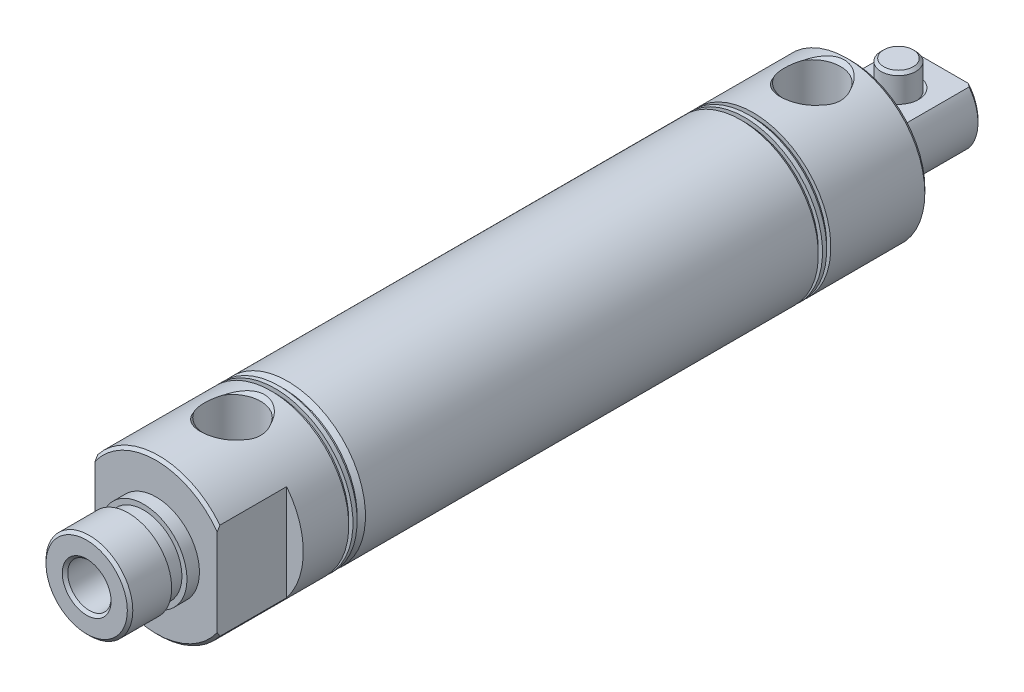
from build123d import *

# Parameters (mm, degrees)
SKETCH1_R           = 14.224
EXTRUDE1_DEPTH      = 71.4375
EXTRUDE1_DEPTH_BACK = 71.4375
SKETCH3_W           = 0.762
SKETCH3_H           = 0.762
RODHOLE_START       = -112.0375
SKETCH8_R           = 3.9624
RODHOLE_DEPTH       = 112.0375
SKETCH9_R           = 13.49375
STROKECHAMBER_DEPTH = 55.8
CHAMFER1_SIZE       = 0.5
SKETCH4_W           = 3.048
SKETCH4_H           = 12.7
SKETCH4_W_2         = 0.5
SKETCH4_H_2         = 6.096
FLATS_DEPTH         = 15.2240001
FLATS_DEPTH_BACK    = 15.2240001
SKETCH12_W          = 9.398
SKETCH12_H          = 15.375
ENDFLATS_DEPTH      = 15.2240001
ENDFLATS_DEPTH_BACK = 15.2240001


with BuildPart() as part:
    # Sketch1 → Extrude1 (new body, two sides)
    with BuildSketch(Plane.XY) as extrude1_sk:
        Circle(SKETCH1_R)
    extrude(amount=EXTRUDE1_DEPTH)
    extrude(extrude1_sk.sketch, amount=-EXTRUDE1_DEPTH_BACK)

    # Sketch2 → Nose (revolve)
    with BuildSketch(Plane(origin=(0, 0, 0), x_dir=(0, 0, -1), z_dir=(1, 0, 0))):
        Polygon((-71.4375, 7.9248), (-73.7235, 7.9248), (-73.7235, 7), (-76.5235, 7), (-76.5235, 7.9375), (-84.1375, 7.9375), (-84.1375, 0), (-71.4375, 0), align=None)
    revolve(axis=Axis((0, 0, 0), (0, 0, 1)))

    # Sketch3 → CoverGrooves (revolve, cut)
    with BuildSketch(Plane(origin=(0, 0, 0), x_dir=(0, 0, -1), z_dir=(1, 0, 0))):
        with Locations((-50.038, 13.843)):
            Rectangle(SKETCH3_W, SKETCH3_H)
        Polygon((-48.895, 14.224), (-48.895, 13.462), (-48.133, 13.462), (-47.371, 14.224), align=None)
        Polygon((37.7405, 14.224), (37.7405, 13.462), (36.9785, 14.224), align=None)
        Polygon((36.2165, 14.224), (36.2165, 13.462), (35.4545, 14.224), align=None)
    revolve(axis=Axis((0, 0, 0), (0, 0, 1)), mode=Mode.SUBTRACT)

    # Sketch7 → FrontPort (revolve, cut)
    with BuildSketch(Plane(origin=(0, 0, 0), x_dir=(0, 0, -1), z_dir=(1, 0, 0))):
        Polygon((-57.4675, 14.224), (-51.6175, 14.224), (-52.3175, 13.524), (-52.3175, 0), (-57.4675, 0), align=None)
    revolve(axis=Axis((0, 0, 57.4675), (0, 1, 0)), mode=Mode.SUBTRACT)

    # Sketch8 → RodHole (cut)
    with BuildSketch(Plane.XY.offset(84.1375).offset(RODHOLE_START)):
        Circle(SKETCH8_R)
    extrude(amount=RODHOLE_DEPTH, mode=Mode.SUBTRACT)

    # Sketch9 → StrokeChamber (cut)
    with BuildSketch(Plane.XY.offset(-27.9)):
        Circle(SKETCH9_R)
    extrude(amount=STROKECHAMBER_DEPTH, mode=Mode.SUBTRACT)

    # Chamfer1
    chamfer1_edges = [part.edges().sort_by_distance(p)[0] for p in [
        (-14.224, 0, -71.4375),
        (-3.9624, 0, 84.1375),
        (-14.224, 0, 71.4375),
        (0, -7.9375, 84.1375),
    ]]
    chamfer(chamfer1_edges, length=CHAMFER1_SIZE)

    # Sketch4 → Flats (cut, two sides)
    with BuildSketch(Plane(origin=(0, 0, 0), x_dir=(1, 0, 0), z_dir=(0, 1, 0))) as flats_sk:
        with Locations((12.7, -65.0875)):
            Rectangle(SKETCH4_W, SKETCH4_H)
        with Locations((13.974, 68.3895)):
            Rectangle(SKETCH4_W_2, SKETCH4_H_2)
        with Locations((-13.974, 68.3895)):
            Rectangle(SKETCH4_W_2, SKETCH4_H_2)
        with Locations((-12.7, -65.0875)):
            Rectangle(SKETCH4_W, SKETCH4_H)
    extrude(amount=FLATS_DEPTH, mode=Mode.SUBTRACT)
    extrude(flats_sk.sketch, amount=-FLATS_DEPTH_BACK, mode=Mode.SUBTRACT)

    # Sketch11 → EndThreads (revolve, cut)
    with BuildSketch(Plane(origin=(0, 0, 0), x_dir=(0, 0, -1), z_dir=(1, 0, 0))):
        Polygon((71.4375, 7.4375), (70.9375, 7.9375), (58.9431, 7.9375), (58.9431, 7), (57.9755, 7), (57.9755, 7.9375), (55.6895, 7.9375), (55.6895, 13.462), (54.9275, 14.224), (71.4375, 14.224), align=None)
    revolve(axis=Axis((0, 0, 0), (0, 0, -1)), mode=Mode.SUBTRACT)

    # Sketch13 → RearTopPort (revolve, cut)
    with BuildSketch(Plane(origin=(0, 0, 0), x_dir=(0, 0, -1), z_dir=(1, 0, 0))):
        Polygon((48.5794, 0), (53.7294, 0), (53.7294, 13.524), (54.4294, 14.224), (48.5794, 14.224), align=None)
    revolve(axis=Axis((0, 0, -48.5794), (0, 1, 0)), mode=Mode.SUBTRACT)

    # Sketch12 → EndFlats (cut, two sides)
    with BuildSketch(Plane(origin=(0, 0, 0), x_dir=(0, -1, 0), z_dir=(1, 0, 0))) as endflats_sk:
        with Locations((9.525, 63.75)):
            Rectangle(SKETCH12_W, SKETCH12_H)
        with Locations((-9.525, 63.75)):
            Rectangle(SKETCH12_W, SKETCH12_H)
    extrude(amount=ENDFLATS_DEPTH, mode=Mode.SUBTRACT)
    extrude(endflats_sk.sketch, amount=-ENDFLATS_DEPTH_BACK, mode=Mode.SUBTRACT)

    # Sketch15 → ClevisPinHole (revolve, cut)
    with BuildSketch(Plane(origin=(0, 0, 0), x_dir=(0, -1, 0), z_dir=(1, 0, 0))):
        Polygon((4.826, 68.0132), (4.326, 67.5132), (-4.326, 67.5132), (-4.826, 68.0132), (-4.826, 64.3255), (4.826, 64.3255), align=None)
    revolve(axis=Axis((0, 0, -64.3255), (0, -1, 0)), mode=Mode.SUBTRACT)

    # Sketch18 → ClevisPin (revolve)
    with BuildSketch(Plane(origin=(0, 0, 0), x_dir=(0, 0, -1), z_dir=(1, 0, 0))):
        Polygon((64.3255, 9.525), (67.0132, 9.525), (67.5132, 9.025), (67.5132, -9.025), (67.0132, -9.525), (64.3255, -9.525), align=None)
    revolve(axis=Axis((0, 0, -64.3255), (0, 1, 0)))


solid = part.part
